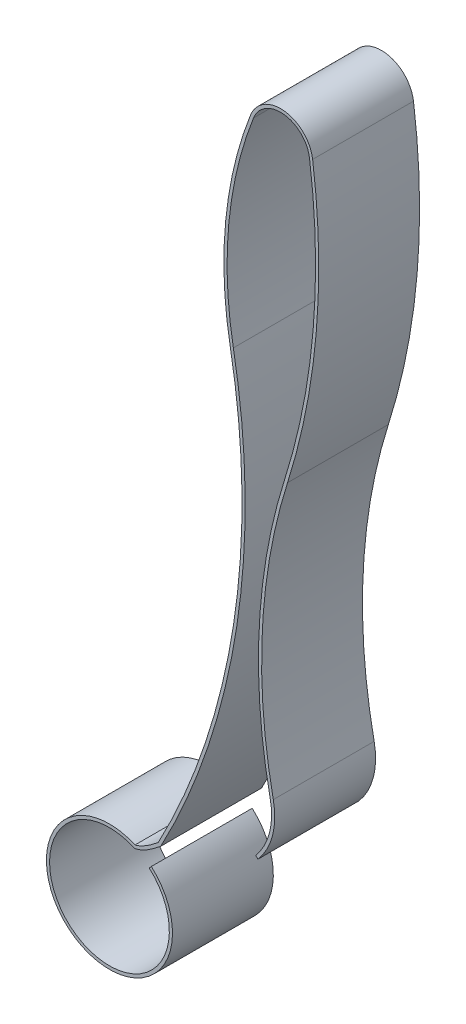
from build123d import *

# Parameters (mm, degrees)
BOSS_EXTRUDE1_DEPTH = 1.6


with BuildPart() as part:
    # Sketch1 → Boss-Extrude1 (new body)
    with BuildSketch(Plane.XY):
        with BuildLine():
            Line((-8.282035958, 14.5722307), (-8.315260994, 14.534866319))
            ThreePointArc((-8.315260994, 14.534866319), (-9.467995528, 13.03085198), (-8.545955906, 14.686357635))
            add(Edge.make_bspline(
                [(-8.545955906, 14.686357635), (-8.479532127, 14.701858549), (-8.371024457, 14.742808946), (-8.203650811, 14.865336036), (-8.133207425, 14.923994424)],
                knots=[-0.055624257, -0.055624257, -0.055624257, -0.055624257, 0.480784626, 1.017193509, 1.017193509, 1.017193509, 1.017193509], degree=3))
            ThreePointArc((-8.133207425, 14.923994424), (-6.928372384, 18.538361158), (-6.980733207, 22.347892982))
            ThreePointArc((-6.980733207, 22.347892982), (-7.052666963, 24.029405703), (-6.661215609, 25.666300731))
            ThreePointArc((-6.661215609, 25.666300731), (-6.175580367, 25.956725815), (-5.772404361, 25.559690017))
            ThreePointArc((-5.772404361, 25.559690017), (-5.715205895, 23.227711177), (-6.169210056, 20.939638365))
            ThreePointArc((-6.169210056, 20.939638365), (-6.571176452, 18.70860829), (-6.395931227, 16.44843987))
            ThreePointArc((-6.395931227, 16.44843987), (-6.407309869, 15.972971601), (-6.627854712, 15.551593481))
            Line((-6.627854712, 15.551593481), (-6.589979408, 15.518952075))
            ThreePointArc((-6.589979408, 15.518952075), (-6.358902268, 15.960453449), (-6.34698023, 16.45862809))
            ThreePointArc((-6.34698023, 16.45862809), (-6.521240039, 18.706087439), (-6.121533926, 20.924572289))
            ThreePointArc((-6.121533926, 20.924572289), (-5.665389298, 23.223432543), (-5.722857434, 25.566405826))
            ThreePointArc((-5.722857434, 25.566405826), (-6.169625674, 26.006369965), (-6.707768814, 25.684543513))
            ThreePointArc((-6.707768814, 25.684543513), (-7.102436785, 24.034197861), (-7.029911938, 22.338867885))
            ThreePointArc((-7.029911938, 22.338867885), (-6.977031108, 18.550865988), (-8.172738286, 14.956142202))
            add(Edge.make_bspline(
                [(-8.540757431, 14.738914192), (-8.391889217, 14.773654662), (-8.172738286, 14.956142202)],
                knots=[0, 0, 0, 1, 1, 1], degree=2))
            ThreePointArc((-8.540757431, 14.738914192), (-9.488127519, 12.984300844), (-8.282035958, 14.5722307))
        make_face()
    extrude(amount=BOSS_EXTRUDE1_DEPTH)


solid = part.part
